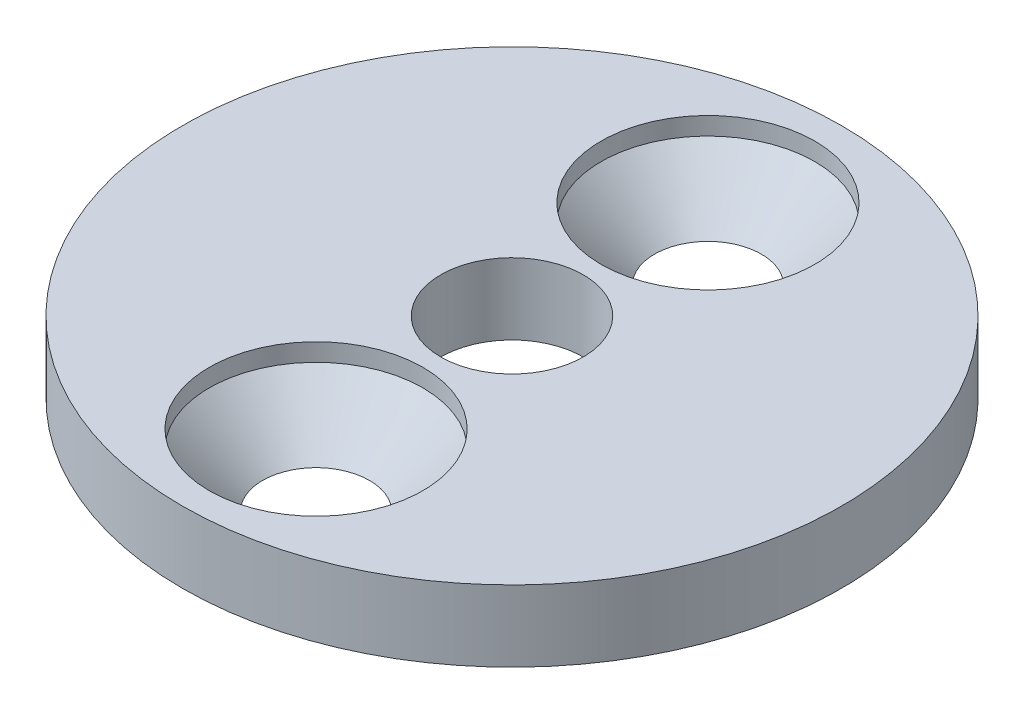
from build123d import *

# Parameters (mm, degrees)
SKETCH1_R           = 9.25
SKETCH1_R_2         = 2
BOSS_EXTRUDE1_DEPTH = 2
CIRPATTERN1_COUNT   = 2


with BuildPart() as part:
    # Sketch1 → Boss-Extrude1 (new body)
    with BuildSketch(Plane(origin=(0, 0, 0), x_dir=(1, 0, 0), z_dir=(0, 1, 0))):
        Circle(SKETCH1_R)
        Circle(SKETCH1_R_2, mode=Mode.SUBTRACT)
    extrude(amount=BOSS_EXTRUDE1_DEPTH)

    # Sketch4 → Cut-Revolve1 (revolve, cut)
    with BuildSketch(Plane(origin=(0, 0, 0), x_dir=(0, 0, -1), z_dir=(1, 0, 0))):
        Polygon((5.5, 0), (5.5, 2), (8.5, 2), (8.5, 1.5), (7, 0), align=None)
    cut_revolve1 = revolve(axis=Axis((0, 2, -5.5), (0, -1, 0)), mode=Mode.SUBTRACT)

    # CirPattern1: Cut-Revolve1 ×2 about axis
    cirpattern1_axis = Axis((0, 0, 0), (0, 1, 0))
    for i in range(1, CIRPATTERN1_COUNT):
        add(cut_revolve1.rotate(cirpattern1_axis, i * 360 / CIRPATTERN1_COUNT), mode=Mode.SUBTRACT)


solid = part.part
